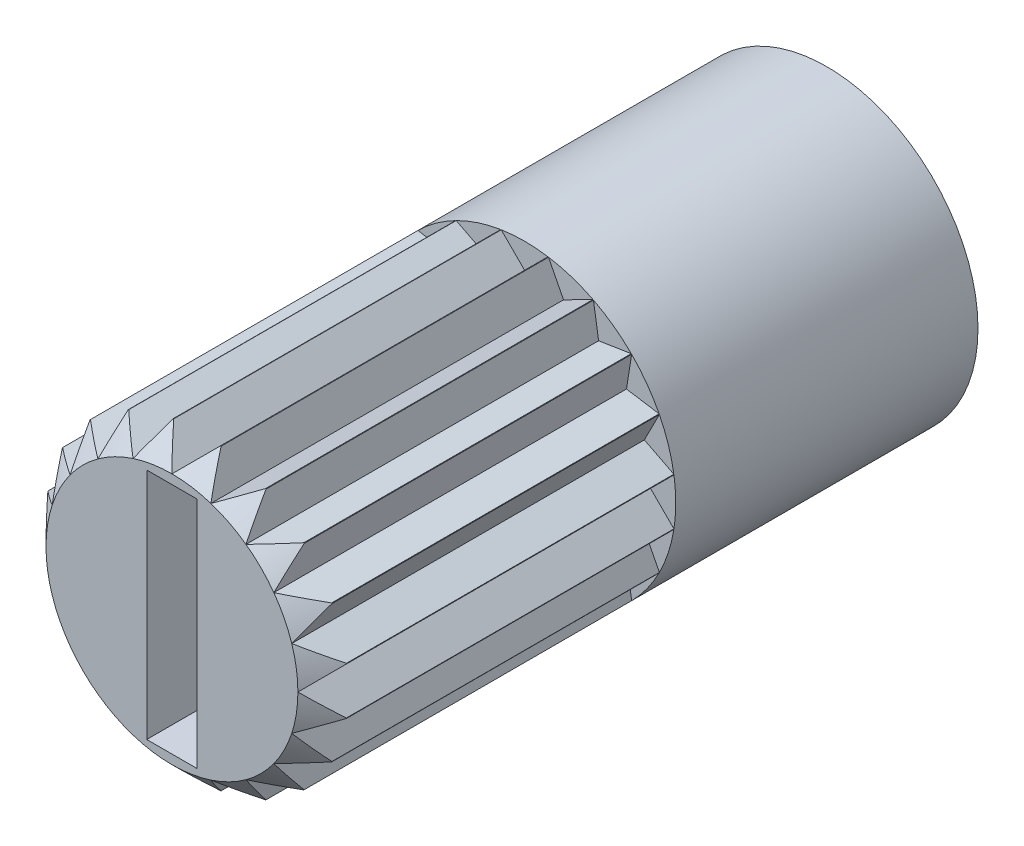
from build123d import *

# Parameters (mm, degrees)
ESQUISSE1_R             = 3
BOSS_EXTRU_1_DEPTH      = 3
BOSS_EXTRU_1_DEPTH_BACK = 10
ESQUISSE3_W             = 1
ESQUISSE3_H             = 4.632353026
ENL_V_MAT_EXTRU_2_DEPTH = 1.5
CHANFREIN1_SIZE         = 0.5
ESQUISSE4_R             = 3.441948867
ENL_V_MAT_EXTRU_3_DEPTH = 7


with BuildPart() as part:
    # Esquisse1 → Boss.-Extru.1 (new body, two sides)
    with BuildSketch(Plane.XY) as boss_extru_1_sk:
        Circle(ESQUISSE1_R)
    extrude(amount=BOSS_EXTRU_1_DEPTH)
    extrude(boss_extru_1_sk.sketch, amount=-BOSS_EXTRU_1_DEPTH_BACK)

    # Esquisse3 → Enlèv. mat.-Extru.2 (cut)
    with BuildSketch(Plane.XY.offset(3)):
        Rectangle(ESQUISSE3_W, ESQUISSE3_H)
    extrude(amount=-ENL_V_MAT_EXTRU_2_DEPTH, mode=Mode.SUBTRACT)

    # Chanfrein1
    chanfrein1_edges = [part.edges().sort_by_distance(p)[0] for p in [
        (-3, 0, 3),
    ]]
    chamfer(chanfrein1_edges, length=CHANFREIN1_SIZE)

    # Esquisse4 → Enlèv. mat.-Extru.3 (cut)
    with BuildSketch(Plane.XY.offset(3)):
        Circle(ESQUISSE4_R)
        Polygon((-2.970477401, -0.470477401), (-2.5, 0), (-2.970477401, 0.470477401), (-2.377641291, 0.772542486), (-2.679706376, 1.365378596), (-2.022542486, 1.469463131), (-2.126627021, 2.126627021), (-1.469463131, 2.022542486), (-1.365378596, 2.679706376), (-0.772542486, 2.377641291), (-0.470477401, 2.970477401), (0, 2.5), (0.470477401, 2.970477401), (0.772542486, 2.377641291), (1.365378596, 2.679706376), (1.469463131, 2.022542486), (2.126627021, 2.126627021), (2.022542486, 1.469463131), (2.679706376, 1.365378596), (2.377641291, 0.772542486), (2.970477401, 0.470477401), (2.5, 0), (2.970477401, -0.470477401), (2.377641291, -0.772542486), (2.679706376, -1.365378596), (2.022542486, -1.469463131), (2.126627021, -2.126627021), (1.469463131, -2.022542486), (1.365378596, -2.679706376), (0.772542486, -2.377641291), (0.470477401, -2.970477401), (0, -2.5), (-0.470477401, -2.970477401), (-0.772542486, -2.377641291), (-1.365378596, -2.679706376), (-1.469463131, -2.022542486), (-2.126627021, -2.126627021), (-2.022542486, -1.469463131), (-2.679706376, -1.365378596), (-2.377641291, -0.772542486), align=None, mode=Mode.SUBTRACT)
    extrude(amount=-ENL_V_MAT_EXTRU_3_DEPTH, mode=Mode.SUBTRACT)


solid = part.part
